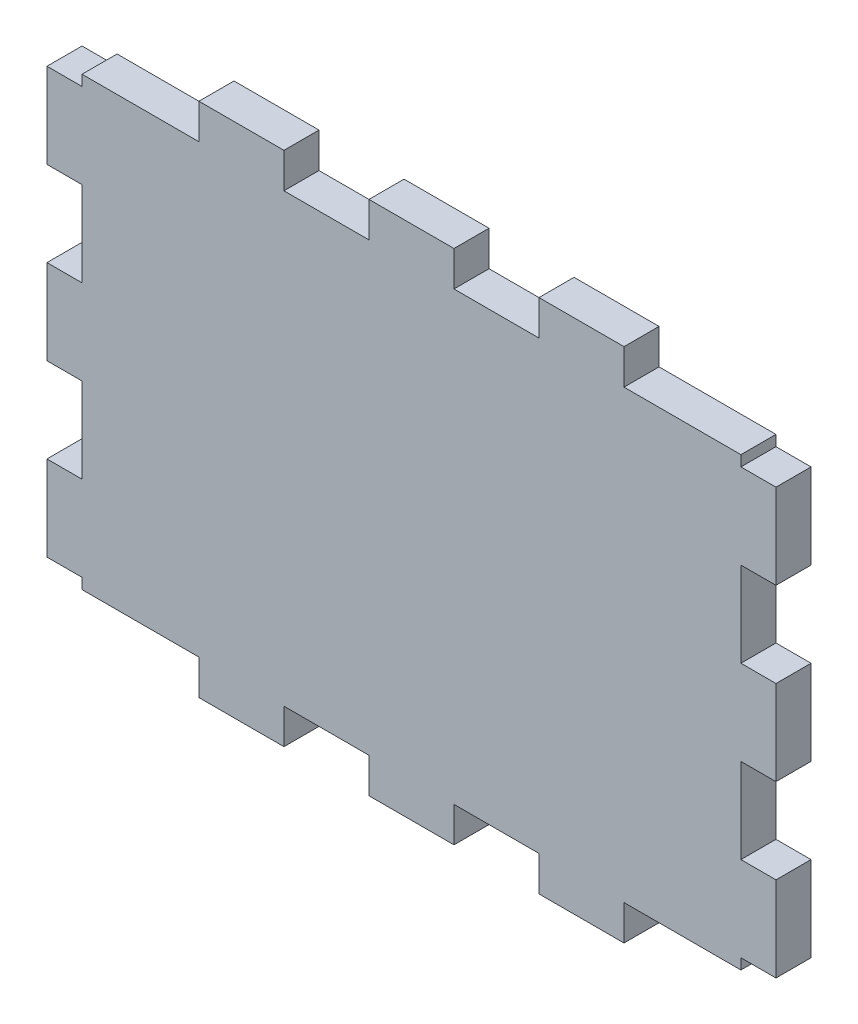
from build123d import *

# Parameters (mm, degrees)
ESQUISSE1_W                    = 62
ESQUISSE1_H                    = 42
BOSS_EXTRU_1_DEPTH             = 3.3
ESQUISSE2_W                    = 8
ESQUISSE2_H                    = 3.3
BOSS_EXTRU_2_DEPTH             = 3.3
R_P_TITION_LIN_AIRE1_COUNT     = 2
R_P_TITION_LIN_AIRE1_PITCH     = 16
R_P_TITION_LIN_AIRE1_COL_COUNT = 2
R_P_TITION_LIN_AIRE1_COL_PITCH = 16
SYM_TRIE1_COPY_1_SKETCH_W      = 8
SYM_TRIE1_COPY_1_SKETCH_H      = 3.3
SYM_TRIE1_COPY_1_DEPTH         = 3.3
SYM_TRIE1_COPY_2_SKETCH_W      = 8
SYM_TRIE1_COPY_2_SKETCH_H      = 3.3
SYM_TRIE1_COPY_2_DEPTH         = 3.3
ESQUISSE3_W                    = 3.3
ESQUISSE3_H                    = 8
BOSS_EXTRU_3_DEPTH             = 3.3
R_P_TITION_LIN_AIRE2_COUNT     = 2
R_P_TITION_LIN_AIRE2_PITCH     = 16
R_P_TITION_LIN_AIRE2_COL_COUNT = 2
R_P_TITION_LIN_AIRE2_COL_PITCH = 16
SYM_TRIE2_COPY_1_SKETCH_W      = 3.3
SYM_TRIE2_COPY_1_SKETCH_H      = 8
SYM_TRIE2_COPY_1_DEPTH         = 3.3
SYM_TRIE2_COPY_2_SKETCH_W      = 3.3
SYM_TRIE2_COPY_2_SKETCH_H      = 8
SYM_TRIE2_COPY_2_DEPTH         = 3.3


with BuildPart() as part:
    # Esquisse1 → Boss.-Extru.1 (new body)
    with BuildSketch(Plane.XY):
        Rectangle(ESQUISSE1_W, ESQUISSE1_H)
    extrude(amount=BOSS_EXTRU_1_DEPTH)

    # Esquisse2 → Boss.-Extru.2 (add)
    with BuildSketch(Plane.XY.offset(3.3)):
        with Locations((0, 22.65)):
            Rectangle(ESQUISSE2_W, ESQUISSE2_H)
    boss_extru_2 = extrude(amount=-BOSS_EXTRU_2_DEPTH)

    # Répétition linéaire1: Boss.-Extru.2 ×2
    with Locations(*[(-i * R_P_TITION_LIN_AIRE1_PITCH, 0, 0) for i in range(1, R_P_TITION_LIN_AIRE1_COUNT)]):
        add(boss_extru_2)

    # Répétition linéaire1 col: Boss.-Extru.2 ×2
    with Locations(*[(i * R_P_TITION_LIN_AIRE1_COL_PITCH, 0, 0) for i in range(1, R_P_TITION_LIN_AIRE1_COL_COUNT)]):
        add(boss_extru_2)

    # Symétrie1: Boss.-Extru.2 across plane
    add(boss_extru_2.mirror(Plane.ZX))

    # Symétrie1 copy 1 sketch → Symétrie1 copy 1 (add)
    with BuildSketch(Plane(origin=(-16, 0, 3.3), x_dir=(1, 0, 0), z_dir=(0, 0, 1))):
        with Locations((0, -22.65)):
            Rectangle(SYM_TRIE1_COPY_1_SKETCH_W, SYM_TRIE1_COPY_1_SKETCH_H)
    extrude(amount=-SYM_TRIE1_COPY_1_DEPTH)

    # Symétrie1 copy 2 sketch → Symétrie1 copy 2 (add)
    with BuildSketch(Plane(origin=(16, 0, 3.3), x_dir=(1, 0, 0), z_dir=(0, 0, 1))):
        with Locations((0, -22.65)):
            Rectangle(SYM_TRIE1_COPY_2_SKETCH_W, SYM_TRIE1_COPY_2_SKETCH_H)
    extrude(amount=-SYM_TRIE1_COPY_2_DEPTH)

    # Esquisse3 → Boss.-Extru.3 (add)
    with BuildSketch(Plane.XY.offset(3.3)):
        with Locations((-32.65, 0)):
            Rectangle(ESQUISSE3_W, ESQUISSE3_H)
    boss_extru_3 = extrude(amount=-BOSS_EXTRU_3_DEPTH)

    # Répétition linéaire2: Boss.-Extru.3 ×2
    with Locations(*[(0, i * R_P_TITION_LIN_AIRE2_PITCH, 0) for i in range(1, R_P_TITION_LIN_AIRE2_COUNT)]):
        add(boss_extru_3)

    # Répétition linéaire2 col: Boss.-Extru.3 ×2
    with Locations(*[(0, -i * R_P_TITION_LIN_AIRE2_COL_PITCH, 0) for i in range(1, R_P_TITION_LIN_AIRE2_COL_COUNT)]):
        add(boss_extru_3)

    # Symétrie2: Boss.-Extru.3 across plane
    add(boss_extru_3.mirror(Plane(origin=(0, 0, 0), x_dir=(0, 0, 1), z_dir=(1, 0, 0))))

    # Symétrie2 copy 1 sketch → Symétrie2 copy 1 (add)
    with BuildSketch(Plane(origin=(0, 16, 3.3), x_dir=(-1, 0, 0), z_dir=(0, 0, 1))):
        with Locations((-32.65, 0)):
            Rectangle(SYM_TRIE2_COPY_1_SKETCH_W, SYM_TRIE2_COPY_1_SKETCH_H)
    extrude(amount=-SYM_TRIE2_COPY_1_DEPTH)

    # Symétrie2 copy 2 sketch → Symétrie2 copy 2 (add)
    with BuildSketch(Plane(origin=(0, -16, 3.3), x_dir=(-1, 0, 0), z_dir=(0, 0, 1))):
        with Locations((-32.65, 0)):
            Rectangle(SYM_TRIE2_COPY_2_SKETCH_W, SYM_TRIE2_COPY_2_SKETCH_H)
    extrude(amount=-SYM_TRIE2_COPY_2_DEPTH)


solid = part.part
